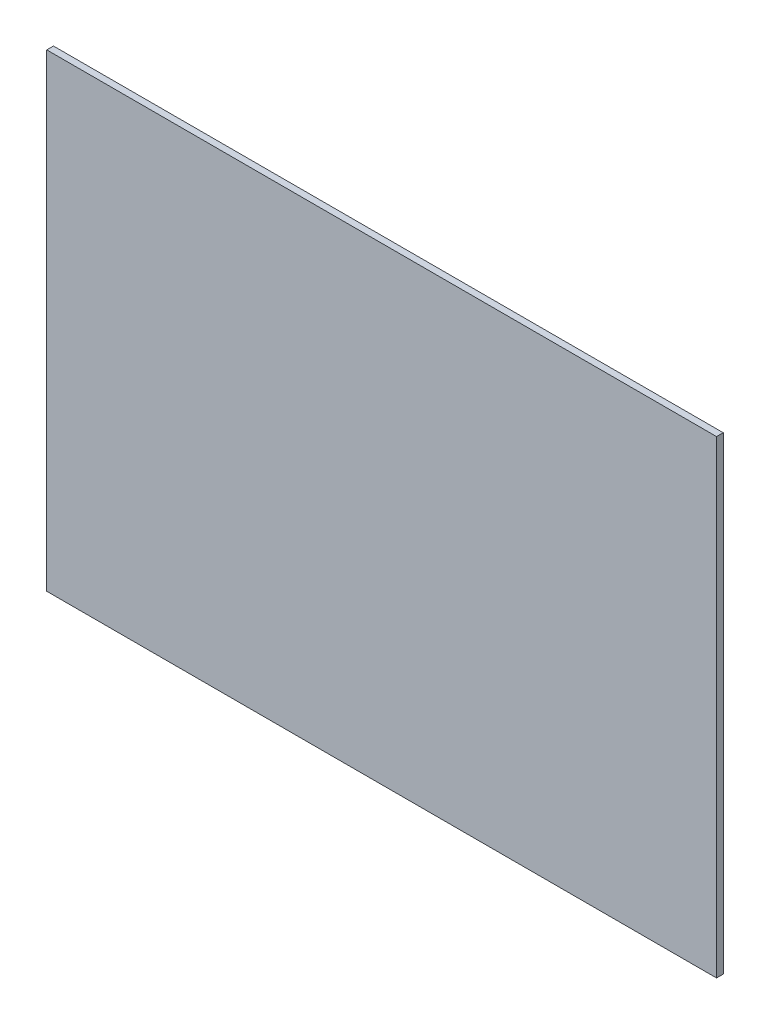
from build123d import *

# Parameters (mm, degrees)
CROQUIS1_W              = 100
CROQUIS1_H              = 70
SALIENTE_EXTRUIR1_DEPTH = 1


with BuildPart() as part:
    # Croquis1 → Saliente-Extruir1 (new body)
    with BuildSketch(Plane.XY):
        with Locations((-12.444130776, -10.515021459)):
            Rectangle(CROQUIS1_W, CROQUIS1_H)
    extrude(amount=SALIENTE_EXTRUIR1_DEPTH)


solid = part.part
